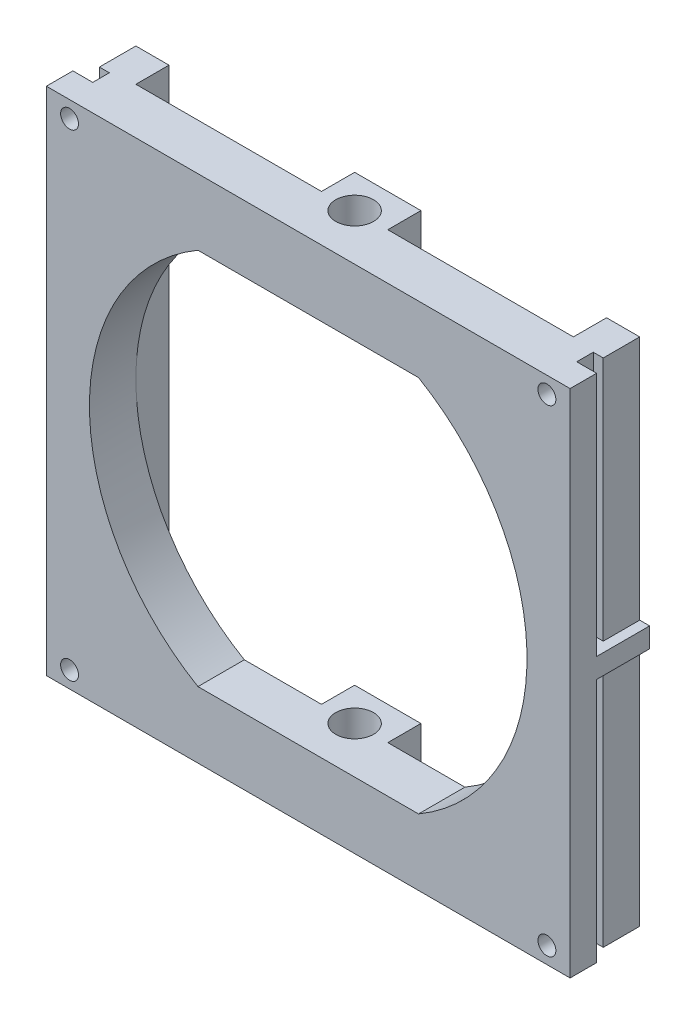
from build123d import *

# Parameters (mm, degrees)
SKETCH1_W           = 79
SKETCH1_H           = 77
BOSS_EXTRUDE1_DEPTH = 12
CUT_EXTRUDE1_DEPTH  = 37
CUT_EXTRUDE2_DEPTH  = 37
SKETCH5_W           = 28
SKETCH5_H           = 5
CUT_EXTRUDE3_DEPTH  = 77
SKETCH7_R           = 2.85
CUT_EXTRUDE5_DEPTH  = 77
SKETCH8_R           = 1.35
CUT_EXTRUDE6_DEPTH  = 4


with BuildPart() as part:
    # Sketch1 → Boss-Extrude1 (new body)
    with BuildSketch(Plane.XY):
        with Locations((39.5, 38.5)):
            Rectangle(SKETCH1_W, SKETCH1_H)
        with BuildLine():
            Line((22.86419524, 67), (56.13580476, 67))
            ThreePointArc((56.13580476, 67), (72.5, 38.5), (56.13580476, 10))
            Line((56.13580476, 10), (22.86419524, 10))
            ThreePointArc((22.86419524, 10), (6.5, 38.5), (22.86419524, 67))
        make_face(mode=Mode.SUBTRACT)
    extrude(amount=BOSS_EXTRUDE1_DEPTH)

    # Sketch3 → Cut-Extrude1 (cut)
    with BuildSketch(Plane.XZ):
        Polygon((0, 0), (1.5, 0), (1.5, 5.5), (3, 5.5), (3, 8), (0, 8), align=None)
        Polygon((79, 0), (77.5, 0), (77.5, 5.5), (76, 5.5), (76, 8), (79, 8), align=None)
    extrude(amount=-CUT_EXTRUDE1_DEPTH, mode=Mode.SUBTRACT)

    # Sketch4 → Cut-Extrude2 (cut)
    with BuildSketch(Plane(origin=(0, 77, 0), x_dir=(1, 0, 0), z_dir=(0, 1, 0))):
        Polygon((76, -8), (79, -8), (79, 0), (77.5, 0), (77.5, -5.5), (76, -5.5), align=None)
        Polygon((0, -8), (3, -8), (3, -5.5), (1.5, -5.5), (1.5, 0), (0, 0), align=None)
    extrude(amount=-CUT_EXTRUDE2_DEPTH, mode=Mode.SUBTRACT)

    # Sketch5 → Cut-Extrude3 (cut)
    with BuildSketch(Plane(origin=(0, 77, 0), x_dir=(1, 0, 0), z_dir=(0, 1, 0))):
        with Locations((58.5, -2.5)):
            Rectangle(SKETCH5_W, SKETCH5_H)
        with Locations((20.5, -2.5)):
            Rectangle(SKETCH5_W, SKETCH5_H)
    extrude(amount=-CUT_EXTRUDE3_DEPTH, mode=Mode.SUBTRACT)

    # Sketch7 → Cut-Extrude5 (cut)
    with BuildSketch(Plane.XZ):
        with Locations((39.5, 5)):
            Circle(SKETCH7_R)
    extrude(amount=-CUT_EXTRUDE5_DEPTH, mode=Mode.SUBTRACT)

    # Sketch8 → Cut-Extrude6 (cut)
    with BuildSketch(Plane.XY.offset(12)):
        with Locations((75.5, 2.5)):
            Circle(SKETCH8_R)
        with Locations((75.5, 74.5)):
            Circle(SKETCH8_R)
        with Locations((3.5, 74.5)):
            Circle(SKETCH8_R)
        with Locations((3.5, 2.5)):
            Circle(SKETCH8_R)
    extrude(amount=-CUT_EXTRUDE6_DEPTH, mode=Mode.SUBTRACT)


solid = part.part
